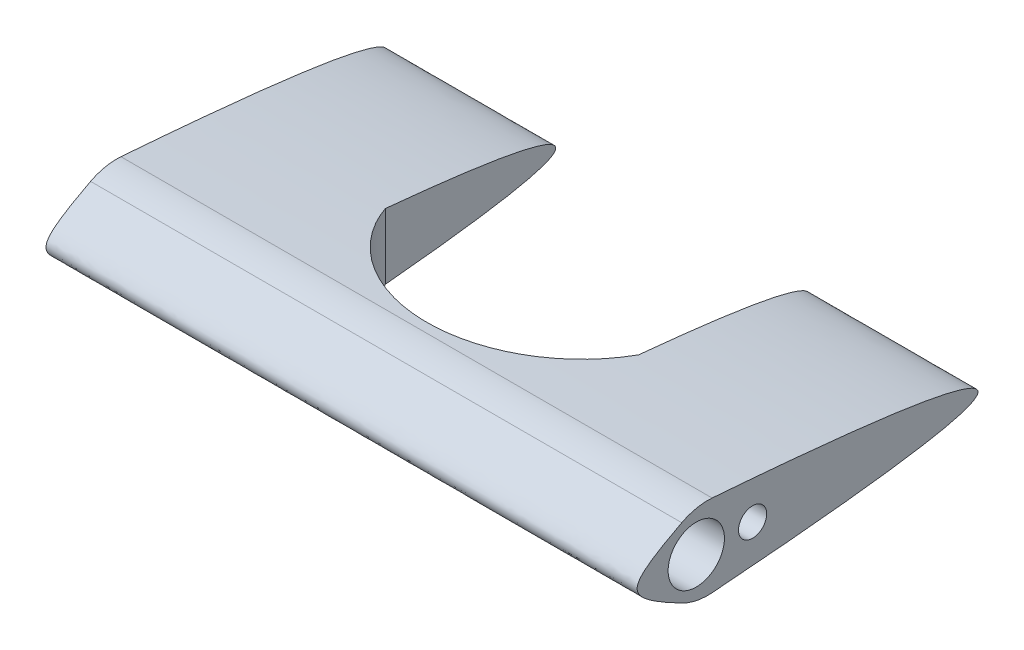
from build123d import *

# Parameters (mm, degrees)
SKETCH1_R               = 5
SKETCH1_R_2             = 2.5
BOSS_EXTRUDE1_DEPTH     = 105
FILLET1_R               = 10
CUT_EXTRUDE1_DEPTH      = 117.542660484
CUT_EXTRUDE1_DEPTH_BACK = 117.542660484


with BuildPart() as part:
    # Sketch1 → Boss-Extrude1 (new body)
    with BuildSketch(Plane(origin=(0, 0, 0), x_dir=(0, 0, -1), z_dir=(1, 0, 0))):
        with BuildLine():
            add(Edge.make_bspline(
                [(3.73e-07, 7.5), (-15, 0), (-3.73e-07, -7.5)],
                knots=[0, 0, 0, 1, 1, 1], degree=2, weights=[1, 2.333333333, 1]))
            add(Edge.make_bspline(
                [(3.73e-07, 7.5), (100, 0), (-3.73e-07, -7.5)],
                knots=[0, 0, 0, 1, 1, 1], degree=2, weights=[1, 1.001467765, 1]))
        make_face()
        Circle(SKETCH1_R, mode=Mode.SUBTRACT)
        with Locations((10, 0)):
            Circle(SKETCH1_R_2, mode=Mode.SUBTRACT)
    extrude(amount=BOSS_EXTRUDE1_DEPTH)

    # Fillet1
    fillet1_edges = [part.edges().sort_by_distance(p)[0] for p in [
        (52.5, 7.5, -3.73e-07),
        (52.5, -7.5, 3.73e-07),
    ]]
    fillet(fillet1_edges, radius=FILLET1_R)

    # Sketch2 → Cut-Extrude1 (cut, two sides)
    with BuildSketch(Plane(origin=(0, 0, 0), x_dir=(1, 0, 0), z_dir=(0, 1, 0))) as cut_extrude1_sk:
        with BuildLine():
            Line((75, 50.03666722), (30, 50.03666722))
            Line((30, 50.03666722), (30, 19.76833361))
            ThreePointArc((30, 19.76833361), (52.5, 4.634166805), (75, 19.76833361))
            Line((75, 19.76833361), (75, 50.03666722))
        make_face()
    extrude(amount=CUT_EXTRUDE1_DEPTH, mode=Mode.SUBTRACT)
    extrude(cut_extrude1_sk.sketch, amount=-CUT_EXTRUDE1_DEPTH_BACK, mode=Mode.SUBTRACT)


solid = part.part
